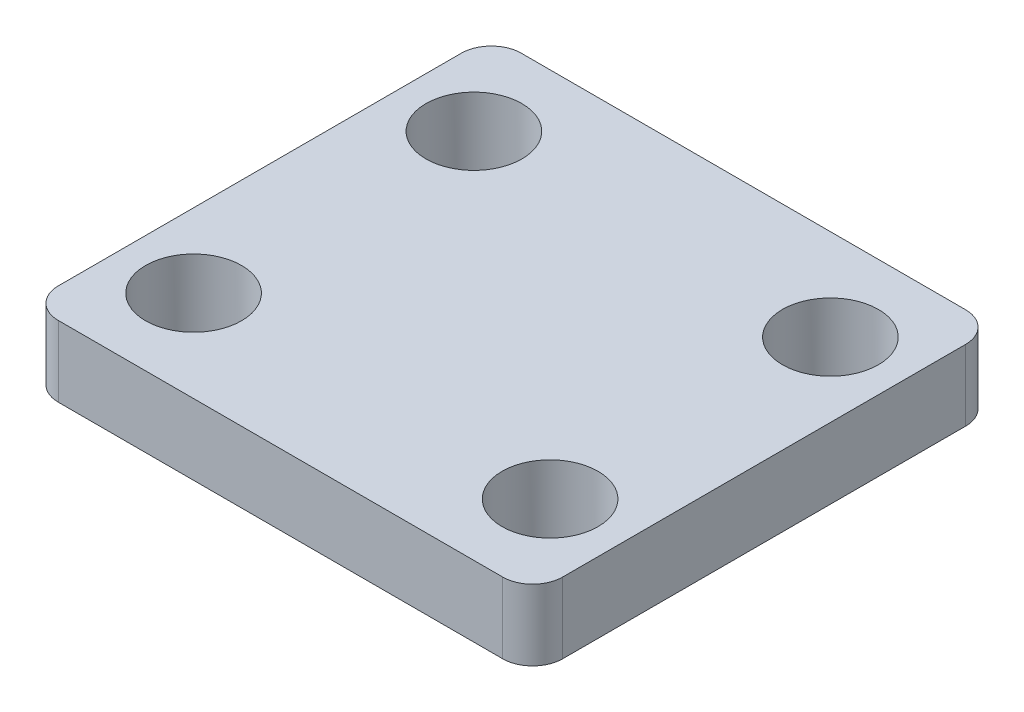
from build123d import *

# Parameters (mm, degrees)
ESQUISSE1_W             = 42.7228
ESQUISSE1_H             = 39.2176
BOSS_EXTRU_1_DEPTH      = 12.573
ENL_V_MAT_EXTRU_1_DEPTH = 40.2176
PER_AGE1_D              = 8.128
PER_AGE1_DEPTH          = 12.573
CONG_1_R                = 0.254
CONG_2_R                = 2.54
ESQUISSE5_W             = 59.007175712
ESQUISSE5_H             = 21.340180089
ENL_V_MAT_EXTRU_2_DEPTH = 43.7228


with BuildPart() as part:
    # Esquisse1 → Boss.-Extru.1 (new body)
    with BuildSketch(Plane(origin=(0, 12.573, 0), x_dir=(1, 0, 0), z_dir=(0, 1, 0))):
        Rectangle(ESQUISSE1_W, ESQUISSE1_H)
    extrude(amount=-BOSS_EXTRU_1_DEPTH)

    # Esquisse2 → Enlèv. mat.-Extru.1 (cut, through all)
    with BuildSketch(Plane(origin=(0, 0, -19.6088), x_dir=(-1, 0, 0), z_dir=(0, 0, -1))):
        Polygon((-9.525, 12.573), (-6.985, 7.493), (6.985, 7.493), (9.525, 12.573), align=None)
    extrude(amount=-ENL_V_MAT_EXTRU_1_DEPTH, mode=Mode.SUBTRACT)

    # Perçage1
    with Locations(Plane(origin=(0, 12.573, 0), x_dir=(1, 0, 0), z_dir=(0, 1, 0))):
        with Locations((15.1003, -11.8745), (-15.1003, 11.8745), (15.1003, 11.8745), (-15.1003, -11.8745)):
            Hole(PER_AGE1_D / 2, depth=PER_AGE1_DEPTH)

    # Congé1
    cong_1_edges = [part.edges().sort_by_distance(p)[0] for p in [
        (9.525, 12.573, 0),
        (-9.525, 12.573, 0),
        (-6.985, 7.493, 0),
        (6.985, 7.493, 0),
    ]]
    fillet(cong_1_edges, radius=CONG_1_R)

    # Congé2
    cong_2_edges = [part.edges().sort_by_distance(p)[0] for p in [
        (21.3614, 6.2865, -19.6088),
        (21.3614, 6.2865, 19.6088),
        (-21.3614, 6.2865, 19.6088),
        (-21.3614, 6.2865, -19.6088),
    ]]
    fillet(cong_2_edges, radius=CONG_2_R)

    # Esquisse5 → Enlèv. mat.-Extru.2 (cut, through all)
    with BuildSketch(Plane(origin=(21.3614, 0, 0), x_dir=(0, 0, -1), z_dir=(1, 0, 0))):
        with Locations((1.148207214, 16.670090045)):
            Rectangle(ESQUISSE5_W, ESQUISSE5_H)
    extrude(amount=-ENL_V_MAT_EXTRU_2_DEPTH, mode=Mode.SUBTRACT)


solid = part.part
